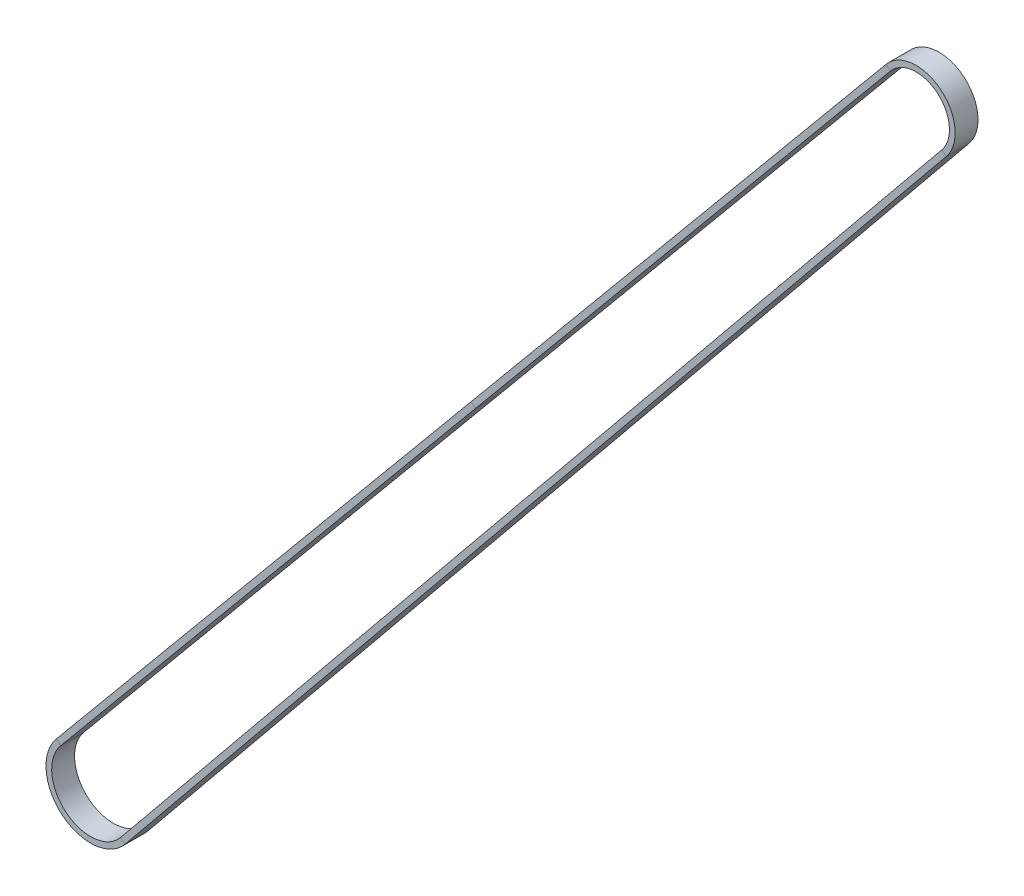
from build123d import *

# Parameters (mm, degrees)
SKETCH2_W = 1.5
SKETCH2_H = 6


with BuildPart() as part:
    # Sweep1: sweep along a path in Sketch1
    with BuildLine(Plane.XY) as sweep1_path:
        Line((209.94266806, 268.776963946), (-7.847039789, 6.51643818))
        ThreePointArc((-7.847039789, 6.51643818), (-6.483002588, -7.874685863), (7.902189472, -6.449449709))
        Line((7.902189472, -6.449449709), (223.453036299, 257.654266002))
        ThreePointArc((223.453036299, 257.654266002), (222.23559657, 269.9421274), (209.94266806, 268.776963946))
    # Sketch2 → Sweep1 (sweep)
    with BuildSketch(Plane(origin=(101.047814135, 137.646701063, 0), x_dir=(-0.769317626, 0.638866488, 0), z_dir=(-0.638866488, -0.769317626, 0))):
        with Locations((0.75, 0)):
            Rectangle(SKETCH2_W, SKETCH2_H)
    sweep(path=sweep1_path.line)


solid = part.part
